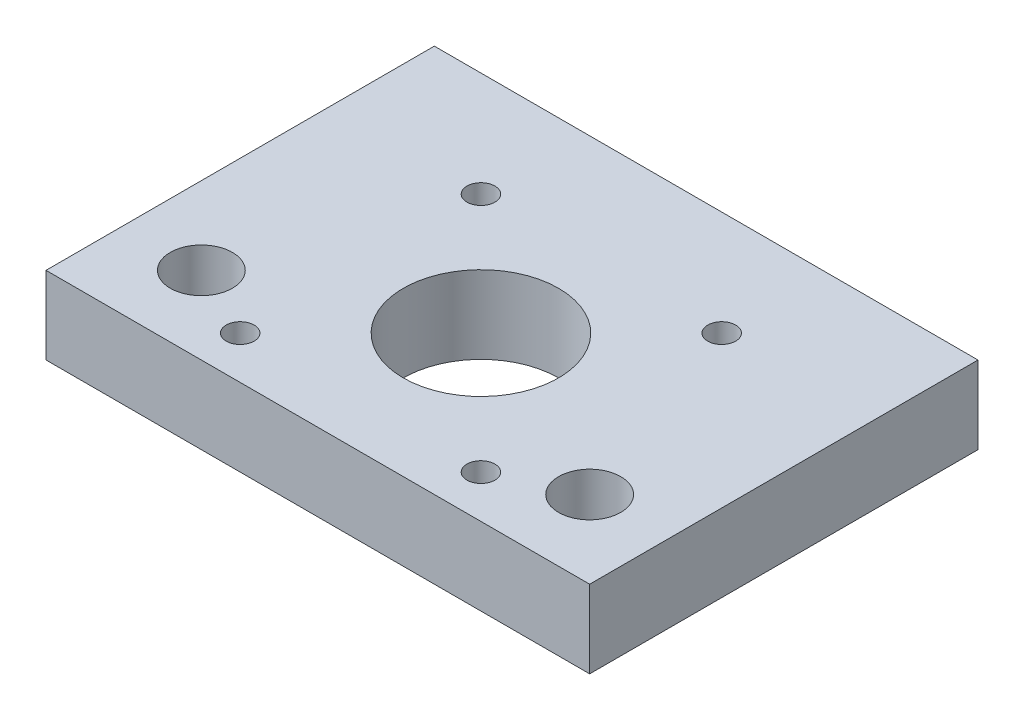
from build123d import *

# Parameters (mm, degrees)
SKETCH2_W                                            = 70
SKETCH2_H                                            = 50
BOSS_EXTRUDE1_DEPTH                                  = 10
SKETCH3_R                                            = 4
CUT_EXTRUDE1_DEPTH                                   = 45.158804332
SKETCH4_R                                            = 1.8
CUT_EXTRUDE2_DEPTH                                   = 45.158804332
SKETCH5_R                                            = 10
CUT_EXTRUDE3_DEPTH                                   = 45.158804332
CSK_FOR_M3_SOCKET_COUNTERSUNK_HEAD_SCREW_D           = 3.4
CSK_FOR_M3_SOCKET_COUNTERSUNK_HEAD_SCREW_CSINK_D     = 6.94
CSK_FOR_M3_SOCKET_COUNTERSUNK_HEAD_SCREW_CSINK_ANGLE = 90


with BuildPart() as part:
    # Sketch2 → Boss-Extrude1 (new body)
    with BuildSketch(Plane(origin=(0, 0, 0), x_dir=(1, 0, 0), z_dir=(0, 1, 0))):
        Rectangle(SKETCH2_W, SKETCH2_H)
    extrude(amount=BOSS_EXTRUDE1_DEPTH)

    # Sketch3 → Cut-Extrude1 (cut, through all)
    with BuildSketch(Plane(origin=(0, 10, 0), x_dir=(1, 0, 0), z_dir=(0, 1, 0))):
        with Locations((-25, -15)):
            Circle(SKETCH3_R)
        with Locations((25, -15)):
            Circle(SKETCH3_R)
    extrude(amount=-CUT_EXTRUDE1_DEPTH, mode=Mode.SUBTRACT)

    # Sketch4 → Cut-Extrude2 (cut, through all)
    with BuildSketch(Plane.XZ):
        with Locations((-15.5, 19.5)):
            Circle(SKETCH4_R)
        with Locations((-15.5, -11.5)):
            Circle(SKETCH4_R)
        with Locations((15.5, -11.5)):
            Circle(SKETCH4_R)
        with Locations((15.5, 19.5)):
            Circle(SKETCH4_R)
    extrude(amount=-CUT_EXTRUDE2_DEPTH, mode=Mode.SUBTRACT)

    # Sketch5 → Cut-Extrude3 (cut, through all)
    with BuildSketch(Plane.XZ):
        with Locations((0, 4)):
            Circle(SKETCH5_R)
    extrude(amount=-CUT_EXTRUDE3_DEPTH, mode=Mode.SUBTRACT)

    # CSK for M3 socket countersunk head screw (through all)
    with Locations(Plane.XZ):
        with Locations((-15.5, 19.5), (15.5, 19.5), (15.5, -11.5), (-15.5, -11.5)):
            CounterSinkHole(CSK_FOR_M3_SOCKET_COUNTERSUNK_HEAD_SCREW_D / 2, CSK_FOR_M3_SOCKET_COUNTERSUNK_HEAD_SCREW_CSINK_D / 2, counter_sink_angle=CSK_FOR_M3_SOCKET_COUNTERSUNK_HEAD_SCREW_CSINK_ANGLE)


solid = part.part
